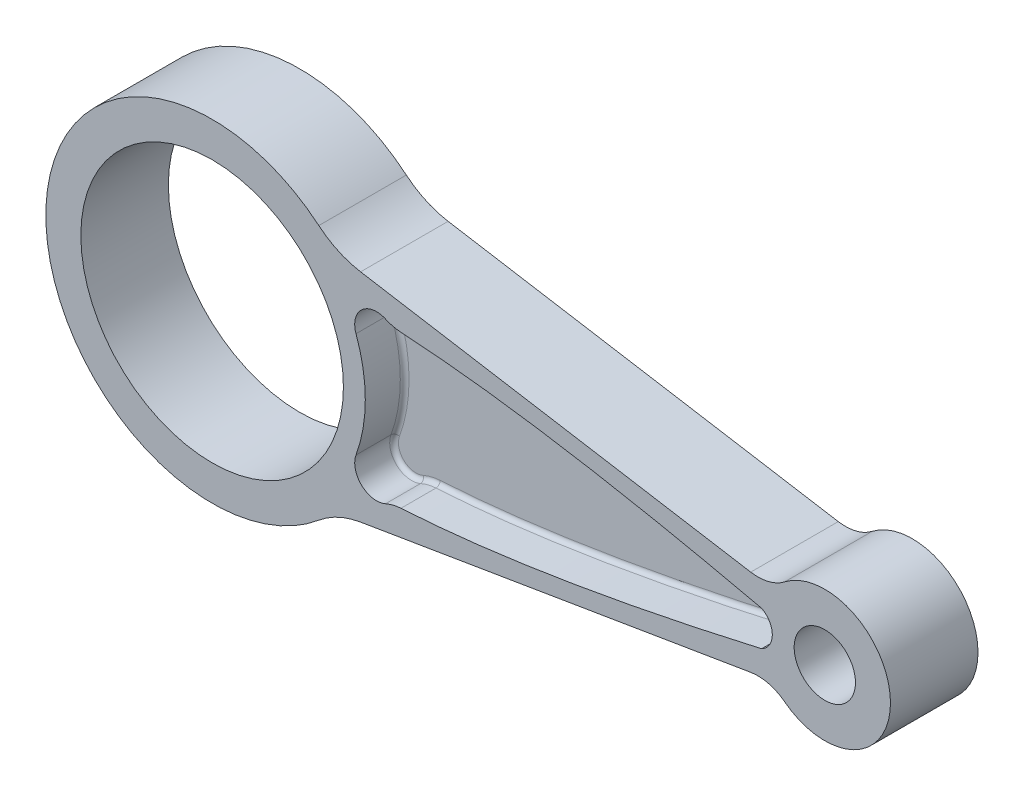
from build123d import *

# Parameters (mm, degrees)
SKETCH1_R           = 30
SKETCH1_R_2         = 7
BOSS_EXTRUDE1_DEPTH = 10
FILLET1_R           = 20
FILLET2_R           = 10
CUT_EXTRUDE1_DEPTH  = 9
FILLET3_R           = 10
FILLET4_R           = 1


with BuildPart() as part:
    # Sketch1 → Boss-Extrude1 (new body, symmetric)
    with BuildSketch(Plane.XY):
        with BuildLine():
            Line((27.935473676, 25.760615491), (128.063755469, 9.084385863))
            ThreePointArc((128.063755469, 9.084385863), (155, 0), (128.063755469, -9.084385863))
            Line((128.063755469, -9.084385863), (27.935473676, -25.760615491))
            ThreePointArc((27.935473676, -25.760615491), (-38, 0), (27.935473676, 25.760615491))
        make_face()
        Circle(SKETCH1_R, mode=Mode.SUBTRACT)
        with Locations((140, 0)):
            Circle(SKETCH1_R_2, mode=Mode.SUBTRACT)
    extrude(amount=BOSS_EXTRUDE1_DEPTH, both=True)

    # Fillet1
    fillet1_edges = [part.edges().sort_by_distance(p)[0] for p in [
        (27.935473676, 25.760615491, 0),
        (27.935473676, -25.760615491, 0),
    ]]
    fillet(fillet1_edges, radius=FILLET1_R)

    # Fillet2
    fillet2_edges = [part.edges().sort_by_distance(p)[0] for p in [
        (128.063755469, 9.084385863, 0),
        (128.063755469, -9.084385863, 0),
    ]]
    fillet(fillet2_edges, radius=FILLET2_R)

    # Sketch2 → Cut-Extrude1 (cut)
    with BuildSketch(Plane(origin=(0, 0, -10), x_dir=(-1, 0, 0), z_dir=(0, 0, -1))):
        with BuildLine():
            ThreePointArc((-32.878564446, -12), (-35, 0), (-32.878564446, 12))
            ThreePointArc((-32.878564446, 12), (-34.711625529, 17.812847691), (-40.800328476, 17.535345206))
            add(Edge.make_bspline(
                [(-40.800328476, 17.535345206), (-73.697249241, 15.932691051), (-125.561552813, 4)],
                knots=[0, 0, 0, 1, 1, 1], degree=2))
            ThreePointArc((-125.561552813, 4), (-128, 0), (-125.561552813, -4))
            add(Edge.make_bspline(
                [(-40.800328476, -17.535345206), (-73.697249241, -15.932691051), (-125.561552813, -4)],
                knots=[0, 0, 0, 1, 1, 1], degree=2))
            ThreePointArc((-40.800328476, -17.535345206), (-34.711625529, -17.812847691), (-32.878564446, -12))
        make_face()
    cut_extrude1 = extrude(amount=-CUT_EXTRUDE1_DEPTH, mode=Mode.SUBTRACT)

    # Mirror1: Cut-Extrude1 across plane
    add(cut_extrude1.mirror(Plane.XY), mode=Mode.SUBTRACT)

    # Fillet3
    fillet3_edges = [part.edges().sort_by_distance(p)[0] for p in [
        (40.800328476, 17.535345206, -5.5),
        (40.800328476, -17.535345206, -5.5),
        (40.800328476, 17.535345206, 5.5),
        (40.800328476, -17.535345206, 5.5),
    ]]
    fillet(fillet3_edges, radius=FILLET3_R)

    # Fillet4
    fillet4_edges = [part.edges().sort_by_distance(p)[0] for p in [
        (34.171453669, -17.376587373, -1),
        (84.610868538, -12.327126764, -1),
        (35, 0, -1),
        (84.610868538, -12.327126764, 1),
        (35, 0, 1),
        (34.171453669, -17.376587373, 1),
        (34.171453669, 17.376587373, 1),
        (84.610868538, 12.327126764, 1),
        (84.610868538, 12.327126764, -1),
        (34.171453669, 17.376587373, -1),
        (41.348581958, 17.680583561, 1),
        (41.348581958, -17.680583561, 1),
        (41.348581958, 17.680583561, -1),
        (41.348581958, -17.680583561, -1),
    ]]
    fillet(fillet4_edges, radius=FILLET4_R)


solid = part.part
